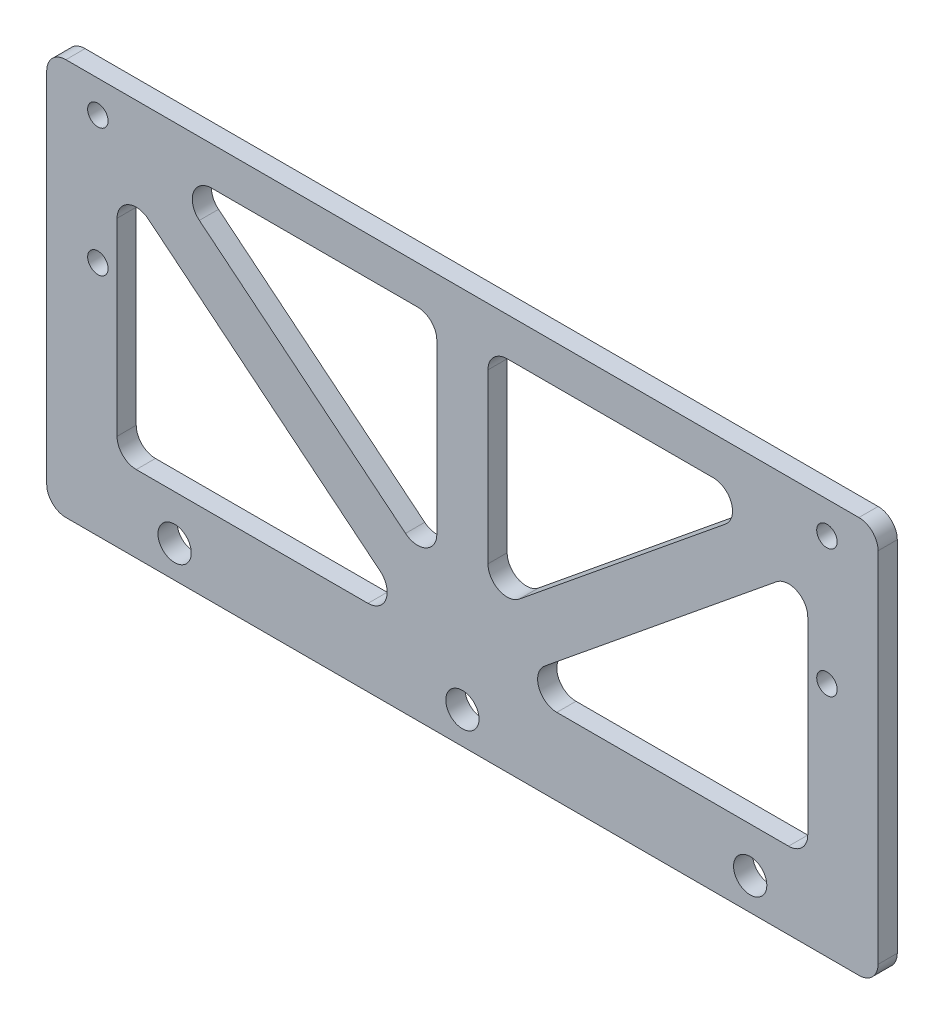
from build123d import *

# Parameters (mm, degrees)
SKETCH_1_W          = 130
SKETCH_1_H          = 62
EXTRUDE_1_DEPTH     = 3
SKETCH_2_R          = 2.6
CUT_EXTRUDE_1_DEPTH = 4
SKETCH_3_R          = 1.6
CUT_EXTRUDE_2_DEPTH = 4
CUT_EXTRUDE_3_DEPTH = 4
FILLET_1_R          = 3
FILLET_2_R          = 3


with BuildPart() as part:
    # 草图1 → 凸台-拉伸1 (new body)
    with BuildSketch(Plane.XY):
        Rectangle(SKETCH_1_W, SKETCH_1_H)
    extrude(amount=EXTRUDE_1_DEPTH)

    # 草图2 → 切除-拉伸1 (cut, through all)
    with BuildSketch(Plane.XY.offset(3)):
        with Locations((-45, -26)):
            Circle(SKETCH_2_R)
        with Locations((0, -26)):
            Circle(SKETCH_2_R)
        with Locations((45, -26)):
            Circle(SKETCH_2_R)
    extrude(amount=-CUT_EXTRUDE_1_DEPTH, mode=Mode.SUBTRACT)

    # 草图3 → 切除-拉伸2 (cut, through all)
    with BuildSketch(Plane.XY.offset(3)):
        with Locations((57, 26)):
            Circle(SKETCH_3_R)
        with Locations((57, 6)):
            Circle(SKETCH_3_R)
    cut_extrude_2 = extrude(amount=-CUT_EXTRUDE_2_DEPTH, mode=Mode.SUBTRACT)

    # 镜向1: 切除-拉伸2 across plane
    add(cut_extrude_2.mirror(Plane(origin=(0, 0, 0), x_dir=(0, 0, 1), z_dir=(1, 0, 0))), mode=Mode.SUBTRACT)

    # 草图4 → 切除-拉伸3 (cut, through all)
    with BuildSketch(Plane.XY.offset(3)):
        Polygon((-6.332390824, -19), (-54, 19.840274143), (-54, -19), align=None)
        Polygon((-4, 25), (-47.667609176, 25), (-4, -10.581014884), align=None)
        Polygon((4, 25), (4, -10.581014884), (47.667609176, 25), align=None)
        Polygon((54, 19.840274143), (6.332390824, -19), (54, -19), align=None)
    extrude(amount=-CUT_EXTRUDE_3_DEPTH, mode=Mode.SUBTRACT)

    # 圆角1
    fillet_1_edges = [part.edges().sort_by_distance(p)[0] for p in [
        (-47.667609176, 25, 1.5),
        (-4, 25, 1.5),
        (-4, -10.581014884, 1.5),
        (4, -10.581014884, 1.5),
        (4, 25, 1.5),
        (47.667609176, 25, 1.5),
        (6.332390824, -19, 1.5),
        (54, 19.840274143, 1.5),
        (54, -19, 1.5),
        (-54, 19.840274143, 1.5),
        (-6.332390824, -19, 1.5),
        (-54, -19, 1.5),
    ]]
    fillet(fillet_1_edges, radius=FILLET_1_R)

    # 圆角2
    fillet_2_edges = [part.edges().sort_by_distance(p)[0] for p in [
        (65, -31, 1.5),
        (-65, -31, 1.5),
        (-65, 31, 1.5),
        (65, 31, 1.5),
    ]]
    fillet(fillet_2_edges, radius=FILLET_2_R)


solid = part.part
